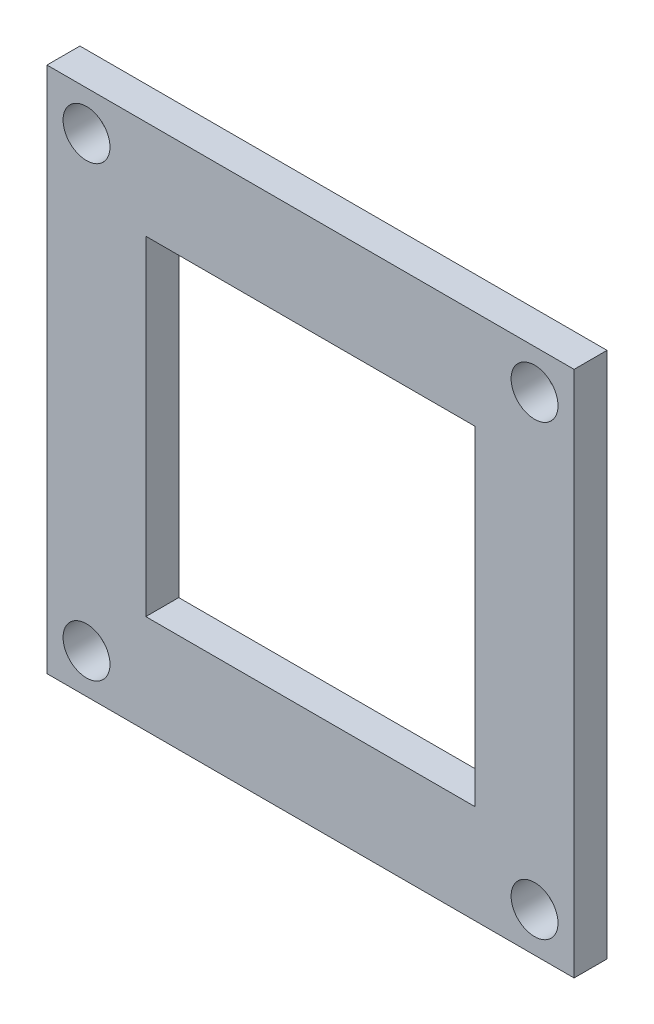
from build123d import *

# Parameters (mm, degrees)
SKETCH1_W             = 25.4
SKETCH1_H             = 25.4
SKETCH1_W_2           = 15.875
SKETCH1_H_2           = 15.875
BOSS_EXTRUDE1_DEPTH   = 1.5875
F_2_CLEARANCE_HOLE1_D = 2.2606


with BuildPart() as part:
    # Sketch1 → Boss-Extrude1 (new body)
    with BuildSketch(Plane.XY):
        Rectangle(SKETCH1_W, SKETCH1_H)
        Rectangle(SKETCH1_W_2, SKETCH1_H_2, mode=Mode.SUBTRACT)
    extrude(amount=BOSS_EXTRUDE1_DEPTH)

    # #2 Clearance Hole1 (through all)
    with Locations(Plane(origin=(-3.354949313, -31.077572016, 1.5875), x_dir=(1, 0, 0), z_dir=(0, 0, 1))):
        with Locations((14.149949313, 41.872572016), (-7.440050687, 41.872572016), (-7.440050687, 20.282572016), (14.149949313, 20.282572016)):
            Hole(F_2_CLEARANCE_HOLE1_D / 2)


solid = part.part
